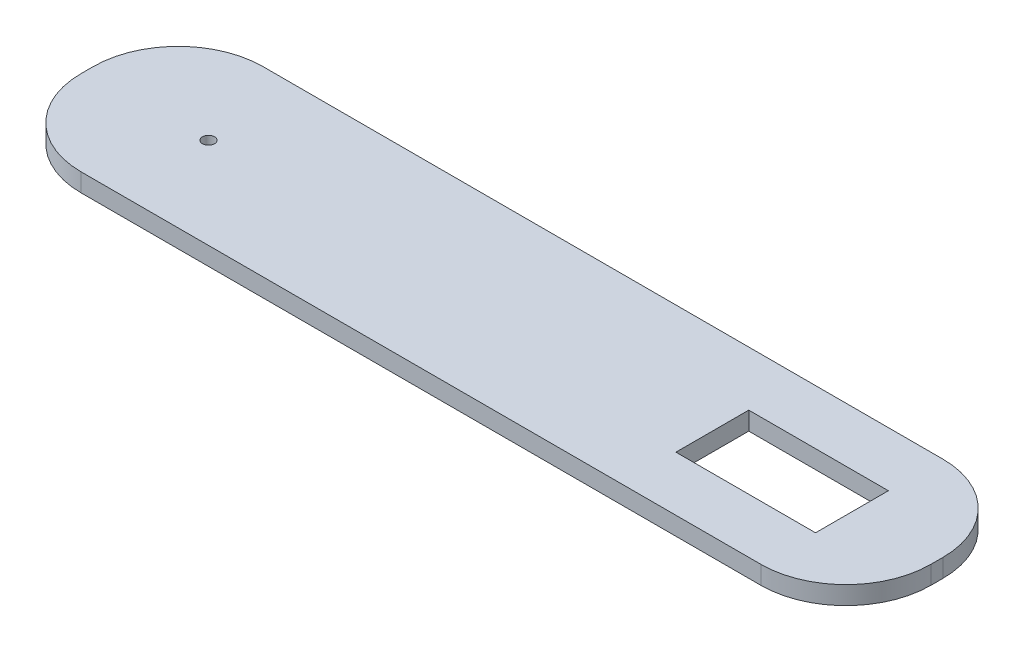
from build123d import *

# Parameters (mm, degrees)
SKETCH1_W           = 140
SKETCH1_H           = 30
BOSS_EXTRUDE1_DEPTH = 3
SKETCH2_R           = 1
SKETCH2_W           = 23
SKETCH2_H           = 12
CUT_EXTRUDE1_DEPTH  = 4
FILLET1_R           = 14


with BuildPart() as part:
    # Sketch1 → Boss-Extrude1 (new body)
    with BuildSketch(Plane(origin=(0, 0, 0), x_dir=(1, 0, 0), z_dir=(0, 1, 0))):
        with Locations((70, 15)):
            Rectangle(SKETCH1_W, SKETCH1_H)
    extrude(amount=BOSS_EXTRUDE1_DEPTH)

    # Sketch2 → Cut-Extrude1 (cut, through all)
    with BuildSketch(Plane(origin=(0, 3, 0), x_dir=(1, 0, 0), z_dir=(0, 1, 0))):
        with Locations((20, 15)):
            Circle(SKETCH2_R)
        with Locations((114.5, 15)):
            Rectangle(SKETCH2_W, SKETCH2_H)
    extrude(amount=-CUT_EXTRUDE1_DEPTH, mode=Mode.SUBTRACT)

    # Fillet1
    fillet1_edges = [part.edges().sort_by_distance(p)[0] for p in [
        (0, 1.5, -30),
        (140, 1.5, -30),
        (140, 1.5, 0),
        (0, 1.5, 0),
    ]]
    fillet(fillet1_edges, radius=FILLET1_R)


solid = part.part
